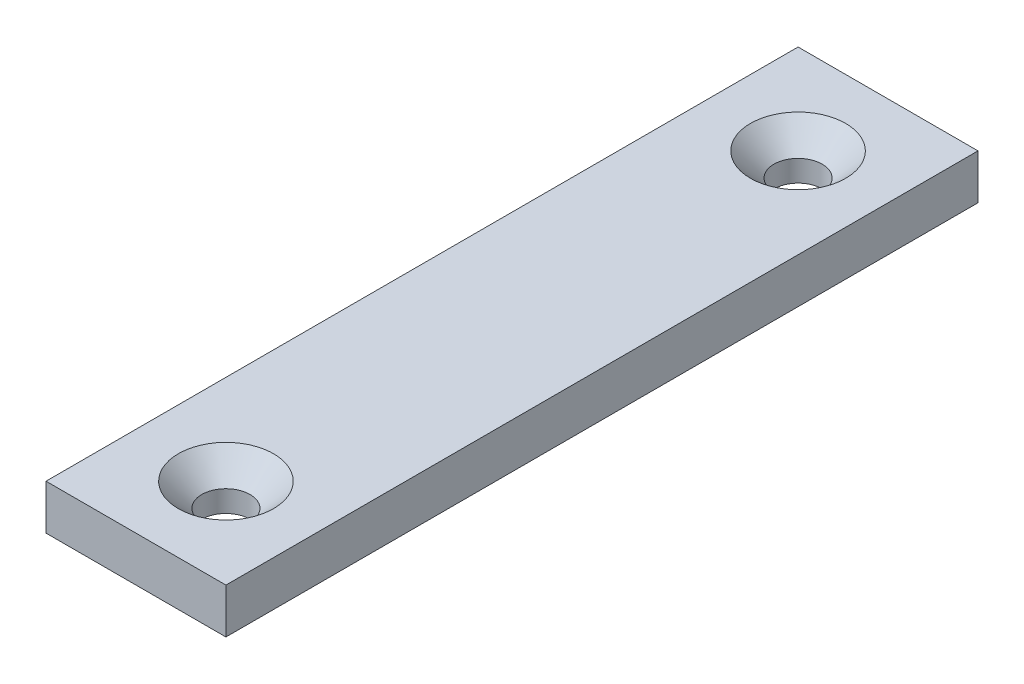
from build123d import *

# Parameters (mm, degrees)
SKETCH1_W                    = 12.7
SKETCH1_H                    = 53.086
BOSS_EXTRUDE1_DEPTH          = 3.175
CSK_FOR_M3_SFHCS1_AT_2_COUNT = 2
CSK_FOR_M3_SFHCS1_AT_2_PITCH = 40.386


with BuildPart() as part:
    # Sketch1 → Boss-Extrude1 (new body)
    with BuildSketch(Plane(origin=(0, 0, 0), x_dir=(1, 0, 0), z_dir=(0, 1, 0))):
        with Locations((6.35, 26.543)):
            Rectangle(SKETCH1_W, SKETCH1_H)
    extrude(amount=BOSS_EXTRUDE1_DEPTH)

    # Sketch2 → CSK for M3 SFHCS1 (revolve, cut)
    with BuildSketch(Plane(origin=(6.35, 3.175, -6.35), x_dir=(0, 0, 1), z_dir=(1, 0, 0))):
        Polygon((0, 0), (0, 3.175), (1.7, 3.175), (1.7, 1.66), (3.36, 0), align=None)
    csk_for_m3_sfhcs1 = revolve(axis=Axis((6.35, 9.525, -6.35), (0, -1, 0)), mode=Mode.SUBTRACT)

    # CSK for M3 SFHCS1 at 2: CSK for M3 SFHCS1 ×2
    with Locations(*[(0, 0, -i * CSK_FOR_M3_SFHCS1_AT_2_PITCH) for i in range(1, CSK_FOR_M3_SFHCS1_AT_2_COUNT)]):
        add(csk_for_m3_sfhcs1, mode=Mode.SUBTRACT)


solid = part.part
